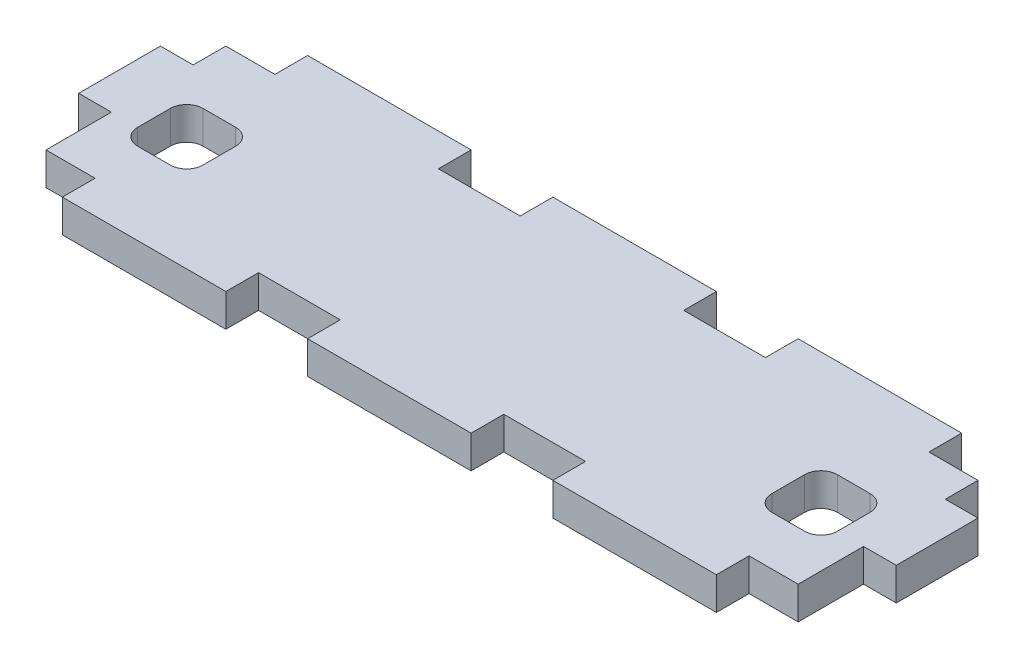
from build123d import *

# Parameters (mm, degrees)
SKETCH1_W           = 127
SKETCH1_H           = 38.1
BOSS_EXTRUDE1_DEPTH = 2.54
SKETCH2_W           = 5.08
SKETCH2_H           = 10.16
SKETCH2_H_2         = 15.24
CUT_EXTRUDE1_DEPTH  = 5.08
SKETCH3_W           = 12.7
SKETCH3_H           = 5.08
CUT_EXTRUDE2_DEPTH  = 5.08
SKETCH4_W           = 12.7
SKETCH4_H           = 5.08
CUT_EXTRUDE4_DEPTH  = 5.08
LPATTERN1_COUNT     = 2
LPATTERN1_PITCH     = 38.1
SKETCH7_W           = 116.84
SKETCH7_H           = 5.08
CUT_EXTRUDE7_DEPTH  = 5.08
SKETCH8_W           = 25.4
SKETCH8_H           = 5.08
BOSS_EXTRUDE2_DEPTH = 5.08
CUT_EXTRUDE8_DEPTH  = 5.08


with BuildPart() as part:
    # Sketch1 → Boss-Extrude1 (new body, symmetric)
    with BuildSketch(Plane(origin=(0, 0, 0), x_dir=(1, 0, 0), z_dir=(0, 1, 0))):
        Rectangle(SKETCH1_W, SKETCH1_H)
    extrude(amount=BOSS_EXTRUDE1_DEPTH, both=True)

    # Sketch2 → Cut-Extrude1 (cut)
    with BuildSketch(Plane(origin=(0, 2.54, 0), x_dir=(1, 0, 0), z_dir=(0, 1, 0))):
        with Locations((-60.96, 13.97)):
            Rectangle(SKETCH2_W, SKETCH2_H)
        with Locations((-60.96, -11.43)):
            Rectangle(SKETCH2_W, SKETCH2_H_2)
    cut_extrude1 = extrude(amount=-CUT_EXTRUDE1_DEPTH, mode=Mode.SUBTRACT)

    # Mirror1: Cut-Extrude1 across plane
    add(cut_extrude1.mirror(Plane(origin=(0, 0, 0), x_dir=(0, 0, 1), z_dir=(1, 0, 0))), mode=Mode.SUBTRACT)

    # Sketch3 → Cut-Extrude2 (cut)
    with BuildSketch(Plane(origin=(0, 2.54, 0), x_dir=(1, 0, 0), z_dir=(0, 1, 0))):
        with Locations((-57.15, -16.51)):
            Rectangle(SKETCH3_W, SKETCH3_H)
    cut_extrude2 = extrude(amount=-CUT_EXTRUDE2_DEPTH, mode=Mode.SUBTRACT)

    # Mirror2: Cut-Extrude2 across plane
    add(cut_extrude2.mirror(Plane(origin=(0, 0, 0), x_dir=(0, 0, 1), z_dir=(1, 0, 0))), mode=Mode.SUBTRACT)

    # Sketch4 → Cut-Extrude4 (cut)
    with BuildSketch(Plane(origin=(0, 2.54, 0), x_dir=(1, 0, 0), z_dir=(0, 1, 0))):
        with Locations((-19.05, -16.51)):
            Rectangle(SKETCH4_W, SKETCH4_H)
    cut_extrude4 = extrude(amount=-CUT_EXTRUDE4_DEPTH, mode=Mode.SUBTRACT)

    # LPattern1: Cut-Extrude4 ×2
    with Locations(*[(i * LPATTERN1_PITCH, 0, 0) for i in range(1, LPATTERN1_COUNT)]):
        add(cut_extrude4, mode=Mode.SUBTRACT)

    # Sketch7 → Cut-Extrude7 (cut)
    with BuildSketch(Plane(origin=(0, 2.54, 0), x_dir=(1, 0, 0), z_dir=(0, 1, 0))):
        with Locations((0, 16.51)):
            Rectangle(SKETCH7_W, SKETCH7_H)
    extrude(amount=-CUT_EXTRUDE7_DEPTH, mode=Mode.SUBTRACT)

    # Sketch8 → Boss-Extrude2 (add)
    with BuildSketch(Plane(origin=(0, 2.54, 0), x_dir=(1, 0, 0), z_dir=(0, 1, 0))):
        with Locations((-38.1, 16.51)):
            Rectangle(SKETCH8_W, SKETCH8_H)
        with Locations((0, 16.51)):
            Rectangle(SKETCH8_W, SKETCH8_H)
        with Locations((38.1, 16.51)):
            Rectangle(SKETCH8_W, SKETCH8_H)
    extrude(amount=-BOSS_EXTRUDE2_DEPTH)

    # Sketch9 → Cut-Extrude8 (cut)
    with BuildSketch(Plane(origin=(0, 2.54, 0), x_dir=(1, 0, 0), z_dir=(0, 1, 0))):
        with BuildLine():
            Line((-51.807363259, 3.81), (-46.727363259, 3.81))
            ThreePointArc((-46.727363259, 3.81), (-44.931312035, 3.066051224), (-44.187363259, 1.27))
            Line((-44.187363259, 1.27), (-44.187363259, -3.81))
            ThreePointArc((-44.187363259, -3.81), (-44.931312035, -5.606051224), (-46.727363259, -6.35))
            Line((-46.727363259, -6.35), (-51.807363259, -6.35))
            ThreePointArc((-51.807363259, -6.35), (-53.603414483, -5.606051224), (-54.347363259, -3.81))
            Line((-54.347363259, -3.81), (-54.347363259, 1.27))
            ThreePointArc((-54.347363259, 1.27), (-53.603414483, 3.066051224), (-51.807363259, 3.81))
        make_face()
    cut_extrude8 = extrude(amount=-CUT_EXTRUDE8_DEPTH, mode=Mode.SUBTRACT)

    # Mirror3: Cut-Extrude8 across plane
    add(cut_extrude8.mirror(Plane(origin=(0, 0, 0), x_dir=(0, 0, 1), z_dir=(1, 0, 0))), mode=Mode.SUBTRACT)


solid = part.part
